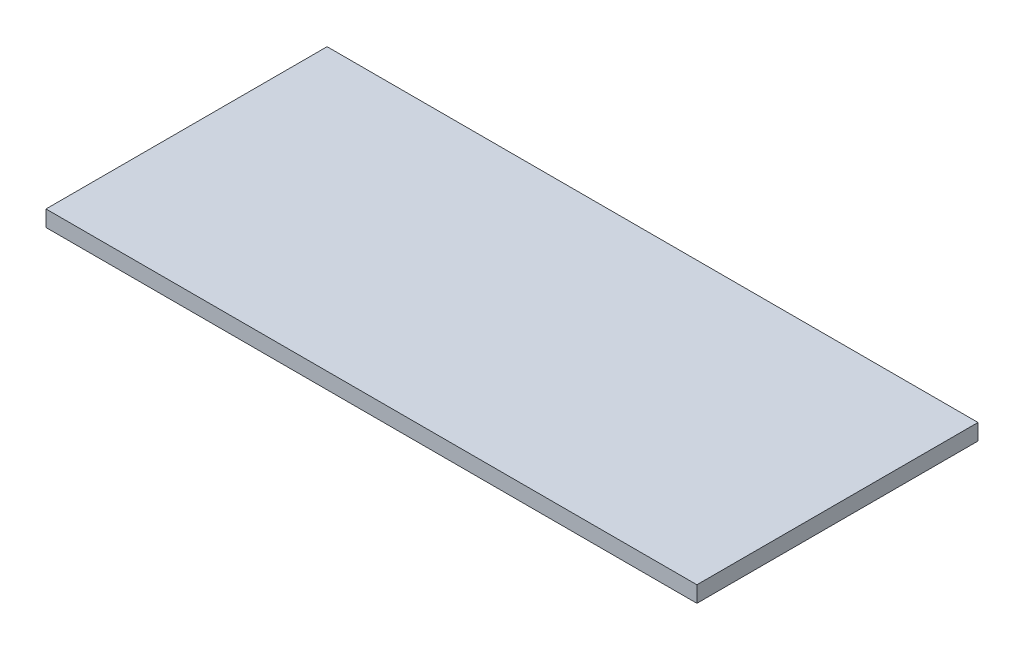
from build123d import *

# Parameters (mm, degrees)
SKETCH1_W           = 2386.746993958
SKETCH1_H           = 564.77151266
BOSS_EXTRUDE1_DEPTH = 71


with BuildPart() as part:
    # Sketch1 → Boss-Extrude1 (new body)
    with BuildSketch(Plane(origin=(0, 0, 0), x_dir=(1, 0, 0), z_dir=(0, 1, 0))):
        Polygon((1731.389962814, -620), (1731.389962814, 620), (1140, 620), (-1140, 620), (-1140, -620), (1140, -620), align=None)
        with Locations((295.694981407, 0)):
            Rectangle(SKETCH1_W, SKETCH1_H, mode=Mode.SUBTRACT)
        with Locations((295.694981407, 0)):
            Rectangle(SKETCH1_W, SKETCH1_H)
    extrude(amount=-BOSS_EXTRUDE1_DEPTH)


solid = part.part
